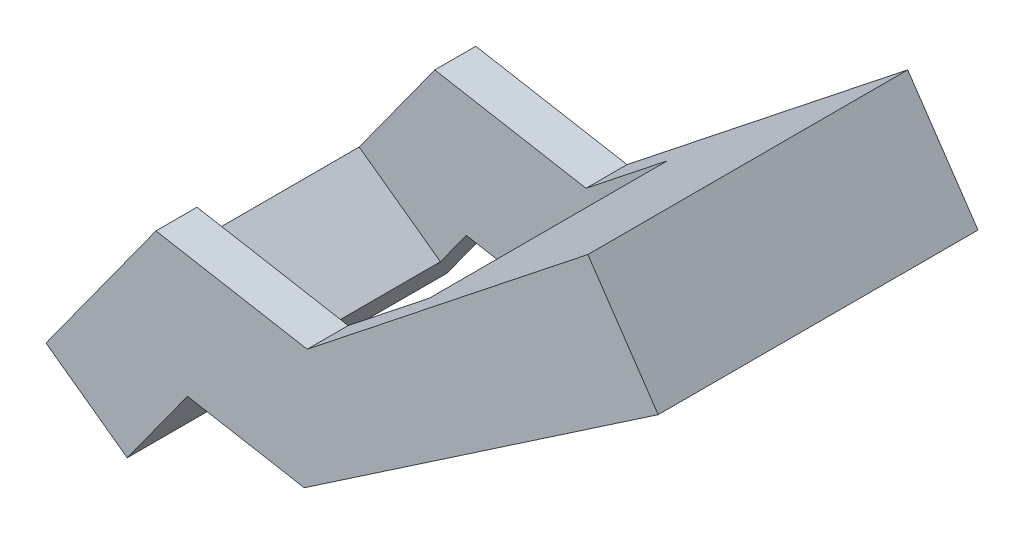
from build123d import *

# Parameters (mm, degrees)
BOSS_EXTRUDE1_DEPTH = 10
BOSS_EXTRUDE2_DEPTH = 29


with BuildPart() as part:
    # Sketch1 → Boss-Extrude1 (new body)
    with BuildSketch(Plane.XY):
        Polygon((3.043765375, 8.102399012), (39.923255905, 1.544552589), (108.379559315, 55.783588702), (125.526610048, 30.521909453), (39.211607002, -28.066742617), (10.726491113, -23.001569193), (-3.966827285, -43.324835363), (-23.780494778, -28.999946703), align=None)
    boss_extrude1 = extrude(amount=-BOSS_EXTRUDE1_DEPTH)

    # Sketch2 → Boss-Extrude2 (add)
    with BuildSketch(Plane(origin=(0, 0, -10), x_dir=(-1, 0, 0), z_dir=(0, 0, -1))):
        Polygon((-59.712812316, 17.224138126), (-74.292234429, -4.25481419), (-125.526610048, 30.521909453), (-108.379559315, 55.783588702), align=None)
        Polygon((23.780494778, -28.999946703), (3.966827285, -43.324835363), (-4.420221287, -31.724173356), (15.393446206, -17.399284696), align=None)
    boss_extrude2 = extrude(amount=BOSS_EXTRUDE2_DEPTH)

    # Mirror1: Boss-Extrude1, Boss-Extrude2 across plane
    add(boss_extrude1.mirror(Plane.XY.offset(-39)))
    add(boss_extrude2.mirror(Plane.XY.offset(-39)))


solid = part.part
